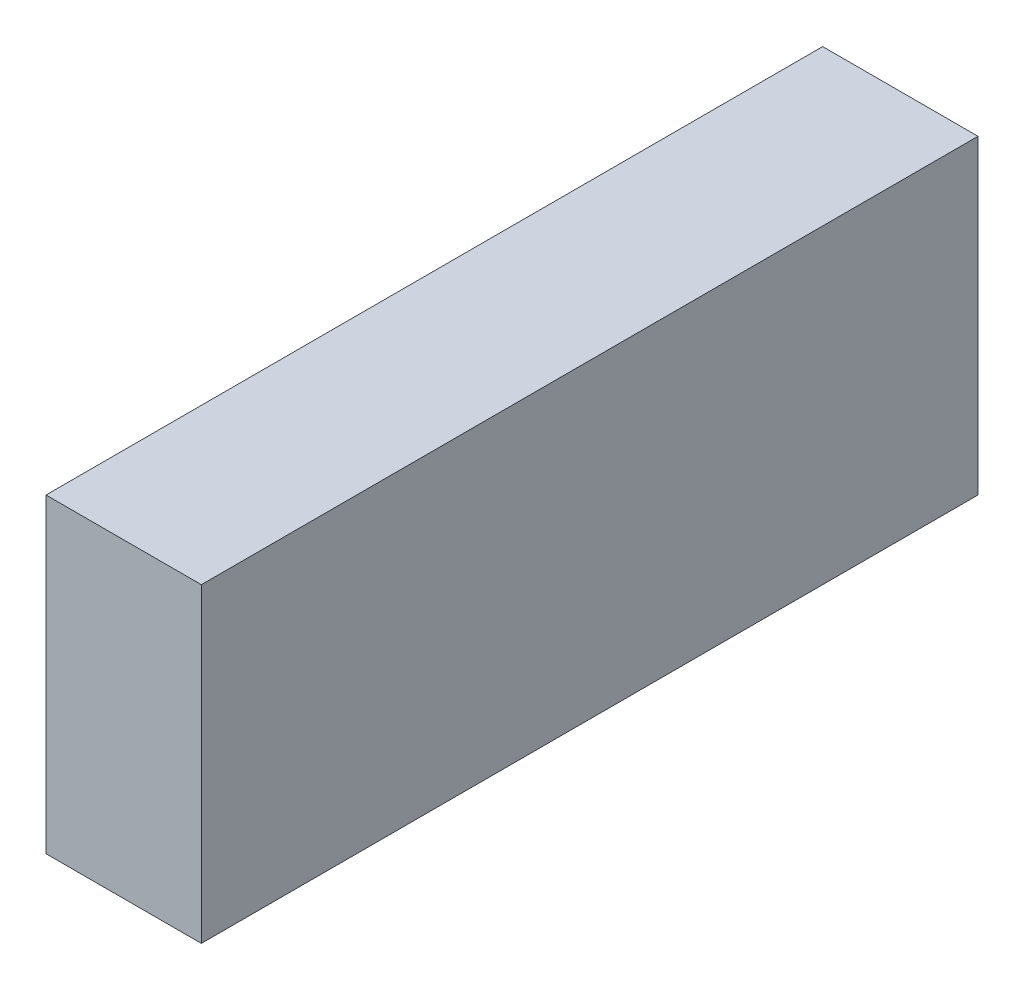
from build123d import *

# Parameters (mm, degrees)
SKIZZE1_W               = 10
SKIZZE1_H               = 20
LINEAR_AUSTRAGEN1_DEPTH = 50


with BuildPart() as part:
    # Skizze1 → Linear austragen1 (new body)
    with BuildSketch(Plane.XY):
        with Locations((5, 10)):
            Rectangle(SKIZZE1_W, SKIZZE1_H)
    extrude(amount=LINEAR_AUSTRAGEN1_DEPTH)


solid = part.part
